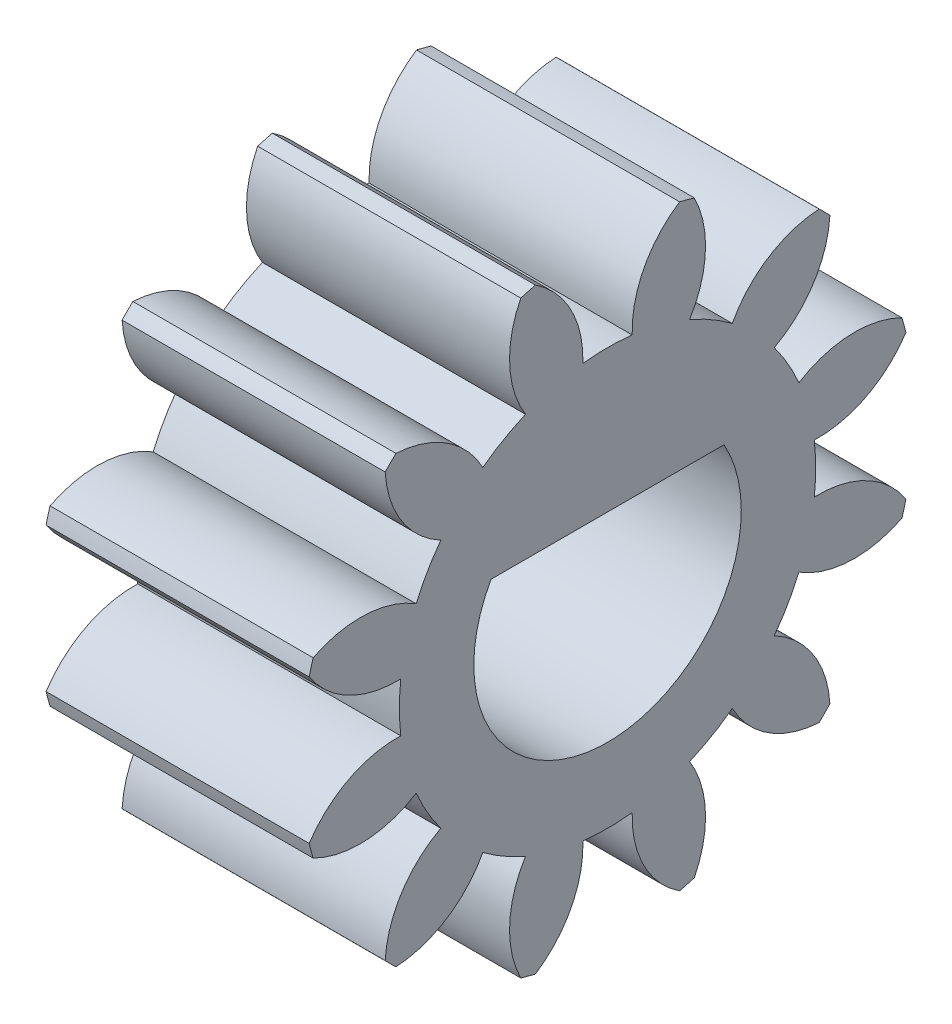
from build123d import *

# Parameters (mm, degrees)
BASPROSKE_W        = 7
BASPROSKE_H        = 7
TOOTHCUT_DEPTH     = 13.124355653
TEETHCUTS_COUNT    = 12
TEETHCUTS_ANGLE    = 330
BORSKE_R           = 0.4
BORE_DEPTH         = 50.0000508
CUT_EXTRUDE1_DEPTH = 12.89949757
SKETCH2_R          = 8.839336396
CUT_EXTRUDE2_DEPTH = 1


with BuildPart() as part:
    # BasProSke → Base-Revolve (revolve)
    with BuildSketch(Plane(origin=(0, 0, 0), x_dir=(1, 0, 0), z_dir=(0, 1, 0)), mode=Mode.PRIVATE) as base_revolve_sk:
        with Locations((3.5, 3.5)):
            Rectangle(BASPROSKE_W, BASPROSKE_H)
    revolve(base_revolve_sk.sketch.rotate(Axis((-10, 0, 0), (1, 0, 0)), 180), axis=Axis((-10, 0, 0), (1, 0, 0)))

    # TooCutSke → ToothCut (cut, through all)
    with BuildSketch(Plane(origin=(0, 0, 0), x_dir=(0, 0, -1), z_dir=(1, 0, 0))):
        with BuildLine():
            ThreePointArc((0.562207301, 4.715604304), (0, 4.749), (-0.562207301, 4.715604304))
            ThreePointArc((-0.562207301, 4.715604304), (-0.837528627, 5.917009812), (-1.672850686, 6.823328788))
            ThreePointArc((-1.672850686, 6.823328788), (0, 7.0254), (1.672850686, 6.823328788))
            ThreePointArc((1.672850686, 6.823328788), (0.837528627, 5.917009812), (0.562207301, 4.715604304))
        make_face()
    toothcut = extrude(amount=TOOTHCUT_DEPTH, mode=Mode.SUBTRACT)

    # TeethCuts: ToothCut ×12 about axis
    teethcuts_axis = Axis((-10, 0, 0), (1, 0, 0))
    for i in range(1, TEETHCUTS_COUNT):
        add(toothcut.rotate(teethcuts_axis, i * TEETHCUTS_ANGLE / (TEETHCUTS_COUNT - 1)), mode=Mode.SUBTRACT)

    # BorSke → Bore (cut, symmetric)
    with BuildSketch(Plane(origin=(0, 0, 0), x_dir=(0, 0, -1), z_dir=(1, 0, 0))):
        with Locations(Location((0, 0, 0), (0, 0, 180))):
            Circle(BORSKE_R)
    extrude(amount=BORE_DEPTH, both=True, mode=Mode.SUBTRACT)

    # Sketch1 → Cut-Extrude1 (cut, through all)
    with BuildSketch(Plane(origin=(7, 0, 0), x_dir=(0, 0, -1), z_dir=(1, 0, 0))):
        with BuildLine():
            Line((-2.655654345, 1.5), (2.655654345, 1.5))
            ThreePointArc((2.655654345, 1.5), (0, -3.05), (-2.655654345, 1.5))
        make_face()
    extrude(amount=-CUT_EXTRUDE1_DEPTH, mode=Mode.SUBTRACT)

    # Sketch2 → Cut-Extrude2 (cut)
    with BuildSketch(Plane.ZY):
        Circle(SKETCH2_R)
    extrude(amount=-CUT_EXTRUDE2_DEPTH, mode=Mode.SUBTRACT)


solid = part.part
